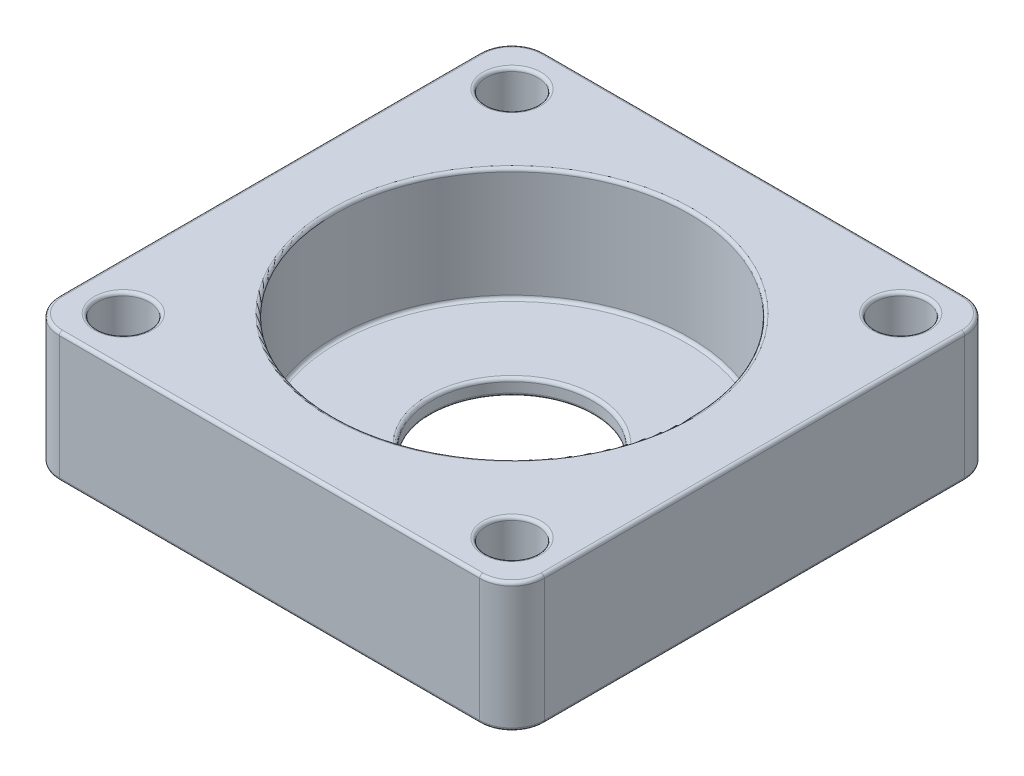
from build123d import *

# Parameters (mm, degrees)
SKETCH1_W           = 30
SKETCH1_H           = 30
SKETCH1_R           = 1.6
SKETCH1_R_2         = 5
BOSS_EXTRUDE1_DEPTH = 8
SKETCH1_3_R         = 11
SKETCH1_3_R_2       = 5
CUT_EXTRUDE1_DEPTH  = 7
FILLET1_R           = 2
FILLET2_R           = 0.2


with BuildPart() as part:
    # Sketch1 → Boss-Extrude1 (new body)
    with BuildSketch(Plane(origin=(0, 0, 0), x_dir=(1, 0, 0), z_dir=(0, 1, 0))):
        Rectangle(SKETCH1_W, SKETCH1_H)
        with Locations((-12.02081528, -12.02081528)):
            Circle(SKETCH1_R, mode=Mode.SUBTRACT)
        with Locations((12.02081528, -12.02081528)):
            Circle(SKETCH1_R, mode=Mode.SUBTRACT)
        with Locations((-12.02081528, 12.02081528)):
            Circle(SKETCH1_R, mode=Mode.SUBTRACT)
        with Locations((12.02081528, 12.02081528)):
            Circle(SKETCH1_R, mode=Mode.SUBTRACT)
        Circle(SKETCH1_R_2, mode=Mode.SUBTRACT)
    extrude(amount=-BOSS_EXTRUDE1_DEPTH)

    # Sketch1_3 → Cut-Extrude1 (cut)
    with BuildSketch(Plane(origin=(0, 0, 0), x_dir=(1, 0, 0), z_dir=(0, 1, 0))):
        Circle(SKETCH1_3_R)
        Circle(SKETCH1_3_R_2, mode=Mode.SUBTRACT)
    extrude(amount=-CUT_EXTRUDE1_DEPTH, mode=Mode.SUBTRACT)

    # Fillet1
    fillet1_edges = [part.edges().sort_by_distance(p)[0] for p in [
        (15, -4, 15),
        (-15, -4, 15),
        (-15, -4, -15),
        (15, -4, -15),
    ]]
    fillet(fillet1_edges, radius=FILLET1_R)

    # Fillet2
    fillet2_edges = [part.edges().sort_by_distance(p)[0] for p in [
        (-5, -8, 0),
        (-13.62081528, -8, 12.02081528),
        (14.414213562, -8, -14.414213562),
        (0, -8, -15),
        (-14.414213562, -8, -14.414213562),
        (-15, -8, 0),
        (-14.414213562, -8, 14.414213562),
        (0, -8, 15),
        (14.414213562, -8, 14.414213562),
        (15, -8, 0),
        (-13.62081528, -8, -12.02081528),
        (10.42081528, -8, -12.02081528),
        (10.42081528, -8, 12.02081528),
        (-11, -7, 0),
        (-5, -7, 0),
        (-13.62081528, 0, 12.02081528),
        (-14.414213562, 0, 14.414213562),
        (-15, 0, 0),
        (-14.414213562, 0, -14.414213562),
        (0, 0, -15),
        (14.414213562, 0, -14.414213562),
        (15, 0, 0),
        (14.414213562, 0, 14.414213562),
        (0, 0, 15),
        (-13.62081528, 0, -12.02081528),
        (10.42081528, 0, -12.02081528),
        (10.42081528, 0, 12.02081528),
        (-11, 0, 0),
    ]]
    fillet(fillet2_edges, radius=FILLET2_R)


solid = part.part
